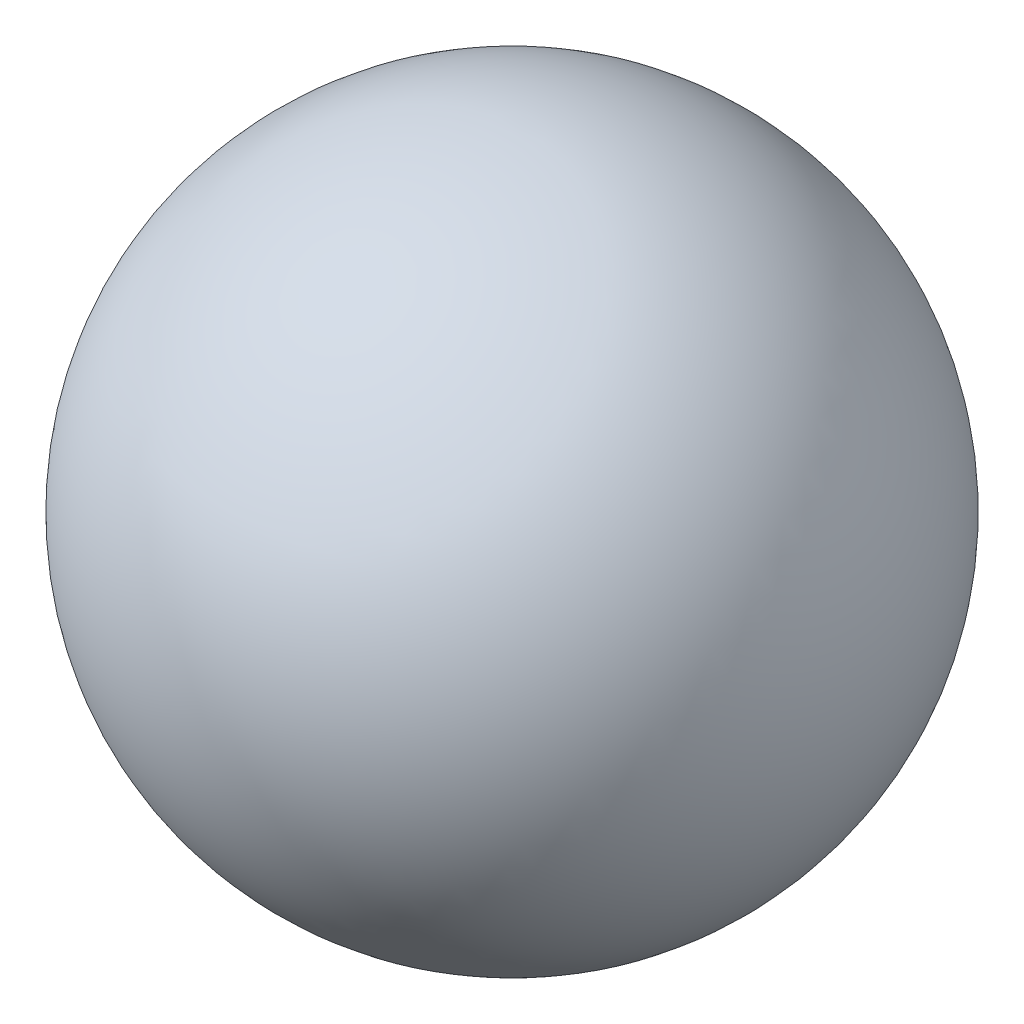
from build123d import *


with BuildPart() as part:
    # Sketch1 → Revolve2 (revolve)
    with BuildSketch(Plane.XY):
        with BuildLine():
            Line((0, 3.575), (0, -3.575))
            ThreePointArc((0, -3.575), (-3.575, 0), (0, 3.575))
        make_face()
    revolve(axis=Axis((0, 3.575, 0), (0, -1, 0)))


solid = part.part
